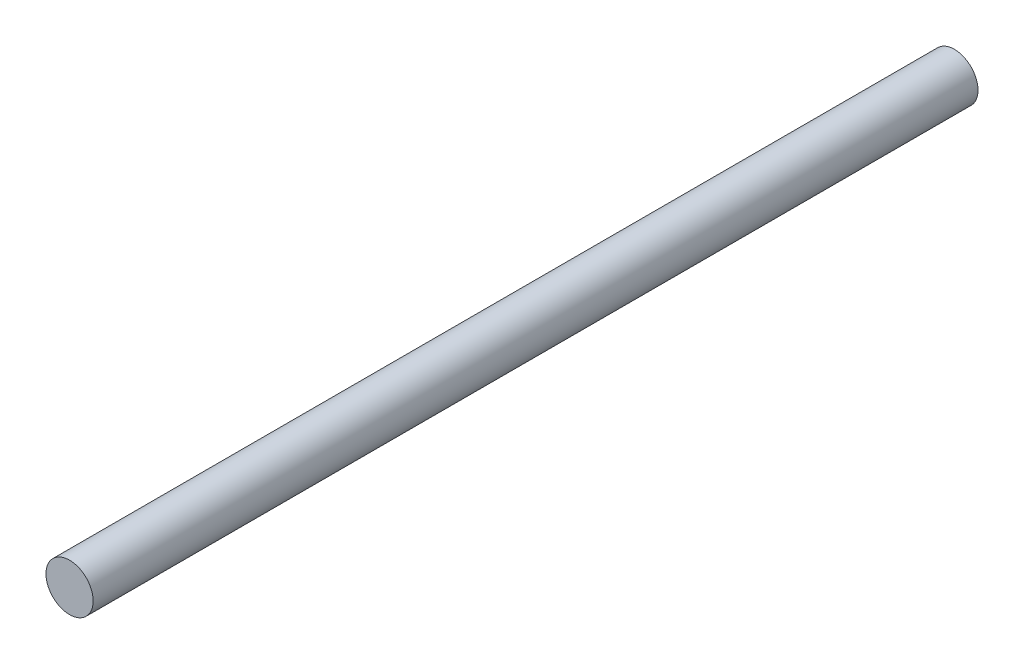
from build123d import *

# Parameters (mm, degrees)
SKETCH_1_R      = 2
EXTRUDE_1_DEPTH = 75


with BuildPart() as part:
    # 草图1 → 凸台-拉伸1 (new body)
    with BuildSketch(Plane.XY):
        Circle(SKETCH_1_R)
    extrude(amount=EXTRUDE_1_DEPTH)


solid = part.part
